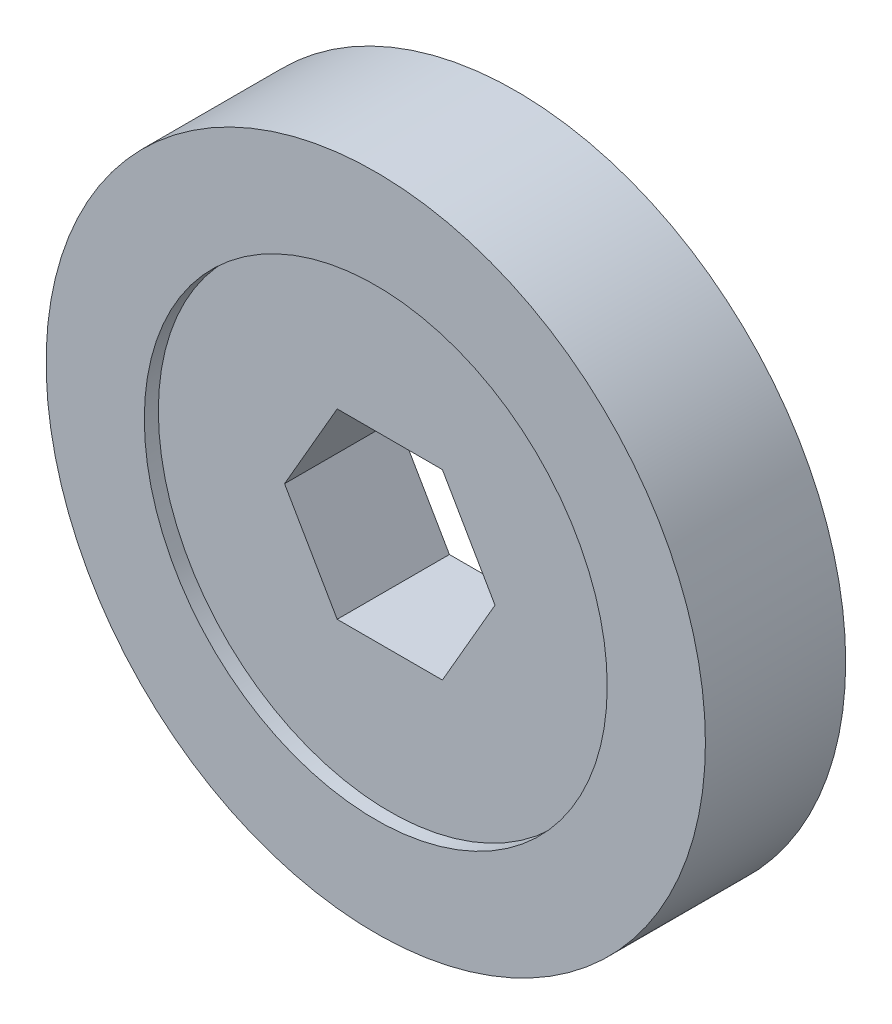
from build123d import *

# Parameters (mm, degrees)
ESQUISSE1_R                = 23.5
BOSS_EXTRU_1_DEPTH         = 10
ENL_V_MAT_EXTRU_1_DEPTH    = 10
ESQUISSE4_R                = 16.5
ENL_V_MAT_EXTRU_2_DEPTH    = 1
R_P_TITION_LIN_AIRE1_COUNT = 2
R_P_TITION_LIN_AIRE1_PITCH = 9


with BuildPart() as part:
    # Esquisse1 → Boss.-Extru.1 (new body)
    with BuildSketch(Plane.XY):
        Circle(ESQUISSE1_R)
    extrude(amount=BOSS_EXTRU_1_DEPTH)

    # Esquisse3 → Enlèv. mat.-Extru.1 (cut)
    with BuildSketch(Plane.XY.offset(10)):
        Polygon((-7.501301233, 0), (-3.749717926, 6.494701961), (3.75, 6.495190528), (7.5, 0), align=None)
    enl_v_mat_extru_1 = extrude(amount=-ENL_V_MAT_EXTRU_1_DEPTH, mode=Mode.SUBTRACT)

    # Symétrie1: Enlèv. mat.-Extru.1 across plane
    add(enl_v_mat_extru_1.mirror(Plane.ZX), mode=Mode.SUBTRACT)

    # Esquisse4 → Enlèv. mat.-Extru.2 (cut)
    with BuildSketch(Plane.XY.offset(10)):
        Circle(ESQUISSE4_R)
    enl_v_mat_extru_2 = extrude(amount=-ENL_V_MAT_EXTRU_2_DEPTH, mode=Mode.SUBTRACT)

    # Répétition linéaire1: Enlèv. mat.-Extru.2 ×2
    with Locations(*[(0, 0, -i * R_P_TITION_LIN_AIRE1_PITCH) for i in range(1, R_P_TITION_LIN_AIRE1_COUNT)]):
        add(enl_v_mat_extru_2, mode=Mode.SUBTRACT)


solid = part.part
